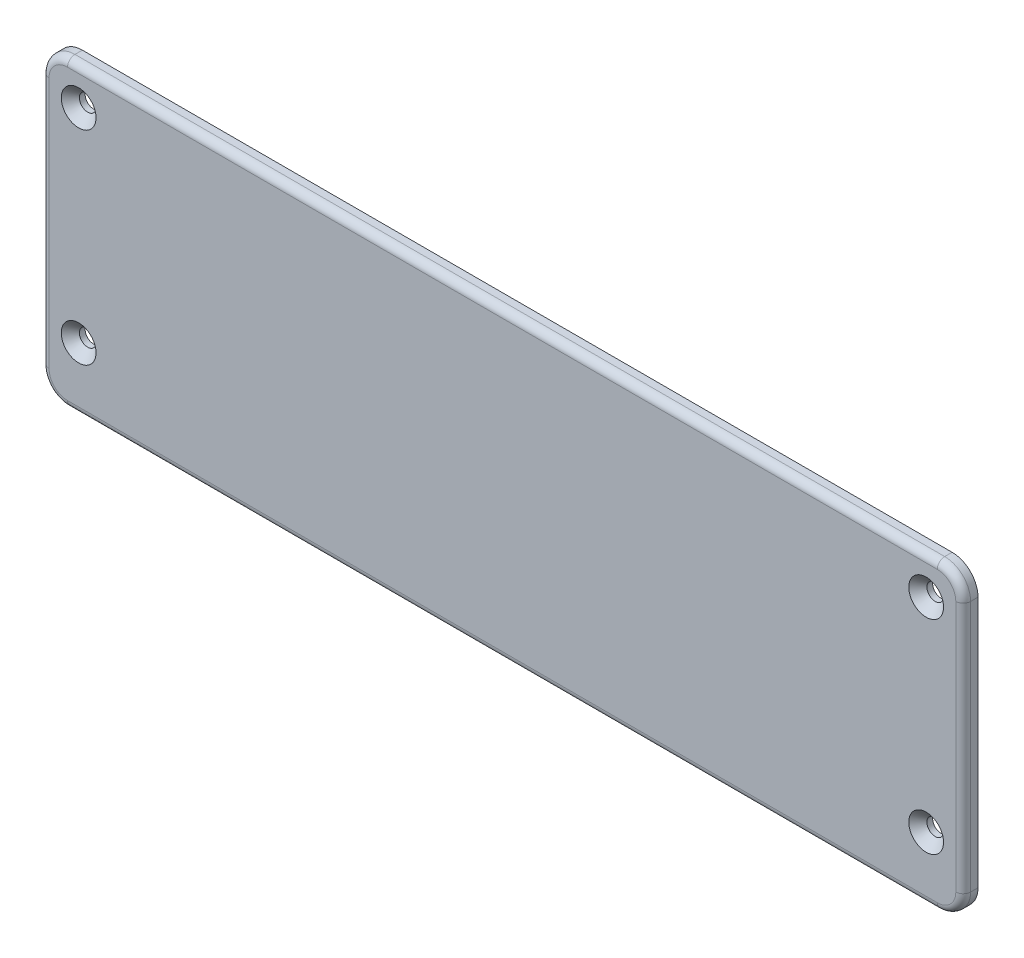
from build123d import *

# Parameters (mm, degrees)
ESQUISSE1_W                                 = 249
ESQUISSE1_H                                 = 82
BOSS_EXTRU_1_DEPTH                          = 4
FRAISAGE_POUR_VIS_T_TE_FRAIS_E_M42_AT_COUNT = 2
FRAISAGE_POUR_VIS_T_TE_FRAIS_E_M42_AT_PITCH = 55
FRAISAGE_POUR_VIS_T_TE_FRAIS_E_M42_2_COUNT  = 2
FRAISAGE_POUR_VIS_T_TE_FRAIS_E_M42_2_PITCH  = 229
FRAISAGE_POUR_VIS_T_TE_FRAIS_E_M42_3_COUNT  = 2
FRAISAGE_POUR_VIS_T_TE_FRAIS_E_M42_3_PITCH  = 235.512207752
CONG_1_R                                    = 7
CONG_2_R                                    = 2


with BuildPart() as part:
    # Esquisse1 → Boss.-Extru.1 (new body)
    with BuildSketch(Plane.XY):
        Rectangle(ESQUISSE1_W, ESQUISSE1_H)
    extrude(amount=BOSS_EXTRU_1_DEPTH)

    # Esquisse6 → Fraisage pour vis à tête fraisée M42 (revolve, cut)
    with BuildSketch(Plane(origin=(-114.5, -24, 4), x_dir=(0, -1, 0), z_dir=(1, 0, 0))):
        Polygon((0, 0), (0, 4), (2.25, 4), (2.25, 2.45), (4.7, 0), align=None)
    fraisage_pour_vis_t_te_frais_e_m42 = revolve(axis=Axis((-114.5, -24, 10.35), (0, 0, -1)), mode=Mode.SUBTRACT)

    # Fraisage pour vis à tête fraisée M42 at: Fraisage pour vis à tête fraisée M42 ×2
    with Locations(*[(0, i * FRAISAGE_POUR_VIS_T_TE_FRAIS_E_M42_AT_PITCH, 0) for i in range(1, FRAISAGE_POUR_VIS_T_TE_FRAIS_E_M42_AT_COUNT)]):
        add(fraisage_pour_vis_t_te_frais_e_m42, mode=Mode.SUBTRACT)

    # Fraisage pour vis _ t_te frais_e M42 2: Fraisage pour vis à tête fraisée M42 ×2
    with Locations(*[(i * FRAISAGE_POUR_VIS_T_TE_FRAIS_E_M42_2_PITCH, 0, 0) for i in range(1, FRAISAGE_POUR_VIS_T_TE_FRAIS_E_M42_2_COUNT)]):
        add(fraisage_pour_vis_t_te_frais_e_m42, mode=Mode.SUBTRACT)

    # Fraisage pour vis _ t_te frais_e M42 3: Fraisage pour vis à tête fraisée M42 ×2
    with Locations(*[Vector(0.972348747, 0.233533542, 0) * (i * FRAISAGE_POUR_VIS_T_TE_FRAIS_E_M42_3_PITCH) for i in range(1, FRAISAGE_POUR_VIS_T_TE_FRAIS_E_M42_3_COUNT)]):
        add(fraisage_pour_vis_t_te_frais_e_m42, mode=Mode.SUBTRACT)

    # Congé1
    cong_1_edges = [part.edges().sort_by_distance(p)[0] for p in [
        (124.5, 41, 2),
        (124.5, -41, 2),
        (-124.5, -41, 2),
        (-124.5, 41, 2),
    ]]
    fillet(cong_1_edges, radius=CONG_1_R)

    # Congé2
    cong_2_edges = [part.edges().sort_by_distance(p)[0] for p in [
        (0, 41, 4),
        (124.5, 0, 4),
        (-124.5, 0, 4),
        (0, -41, 4),
        (-122.449747468, 38.949747468, 4),
        (-122.449747468, -38.949747468, 4),
        (122.449747468, -38.949747468, 4),
        (122.449747468, 38.949747468, 4),
    ]]
    fillet(cong_2_edges, radius=CONG_2_R)


solid = part.part
